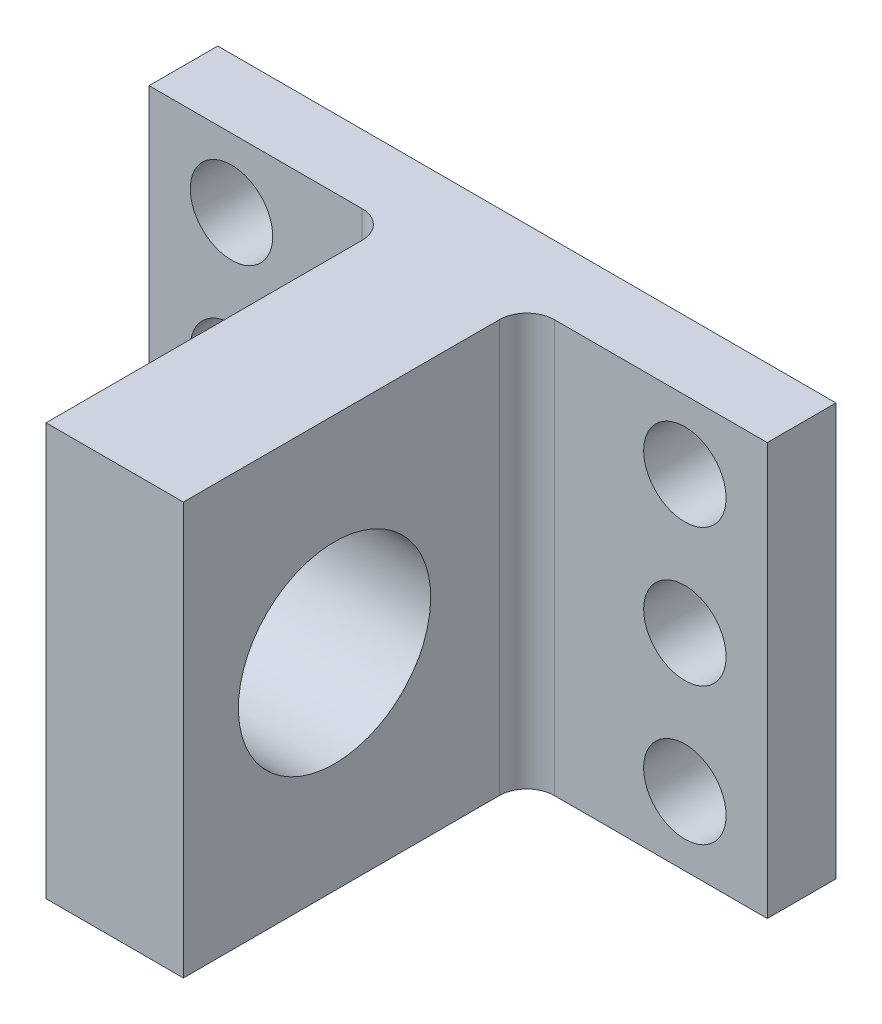
from build123d import *

# Parameters (mm, degrees)
SKETCH1_W           = 45
SKETCH1_H           = 30
BASE_DEPTH          = 5
SKETCH2_W           = 10
SKETCH2_H           = 30
BOSS_EXTRUDE2_DEPTH = 25
SKETCH3_R           = 7
CUT_EXTRUDE3_DEPTH  = 10
SKETCH9_R           = 3
SCREW_DEPTH         = 5
FILLET1_R           = 2
FILLET2_R           = 2


with BuildPart() as part:
    # Sketch1 → Base (new body)
    with BuildSketch(Plane.XY):
        Rectangle(SKETCH1_W, SKETCH1_H)
    extrude(amount=BASE_DEPTH)

    # Sketch2 → Boss-Extrude2 (add)
    with BuildSketch(Plane.XY.offset(5)):
        Rectangle(SKETCH2_W, SKETCH2_H)
    extrude(amount=BOSS_EXTRUDE2_DEPTH)

    # Sketch3 → Cut-Extrude3 (cut)
    with BuildSketch(Plane.ZY.offset(5)):
        with Locations((19, 0)):
            Circle(SKETCH3_R)
    extrude(amount=-CUT_EXTRUDE3_DEPTH, mode=Mode.SUBTRACT)

    # Sketch9 → Screw (cut)
    with BuildSketch(Plane.XY.offset(5)):
        with Locations((-16.5, 10)):
            Circle(SKETCH9_R)
        with Locations((-16.5, 0)):
            Circle(SKETCH9_R)
        with Locations((-16.5, -10)):
            Circle(SKETCH9_R)
        with Locations((16.5, -10)):
            Circle(SKETCH9_R)
        with Locations((16.5, 0)):
            Circle(SKETCH9_R)
        with Locations((16.5, 10)):
            Circle(SKETCH9_R)
    extrude(amount=-SCREW_DEPTH, mode=Mode.SUBTRACT)

    # Fillet1
    fillet1_edges = [part.edges().sort_by_distance(p)[0] for p in [
        (-5, 0, 5),
    ]]
    fillet(fillet1_edges, radius=FILLET1_R)

    # Fillet2
    fillet2_edges = [part.edges().sort_by_distance(p)[0] for p in [
        (5, 0, 5),
    ]]
    fillet(fillet2_edges, radius=FILLET2_R)


solid = part.part
